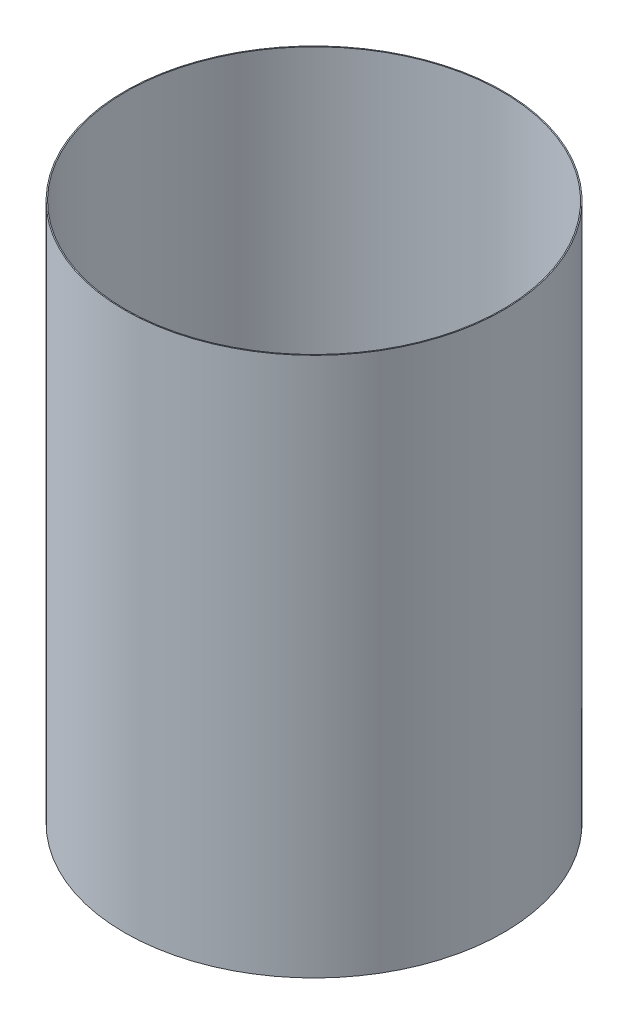
from build123d import *

# Parameters (mm, degrees)
SKETCH1_W = 0.254
SKETCH1_H = 133.35


with BuildPart() as part:
    # Sketch1 → Revolve-Thin1 (revolve)
    with BuildSketch(Plane.XY):
        with Locations((-46.736, -86.580914232)):
            Rectangle(SKETCH1_W, SKETCH1_H)
    revolve(axis=Axis((0, 55, 0), (0, -1, 0)))


solid = part.part
